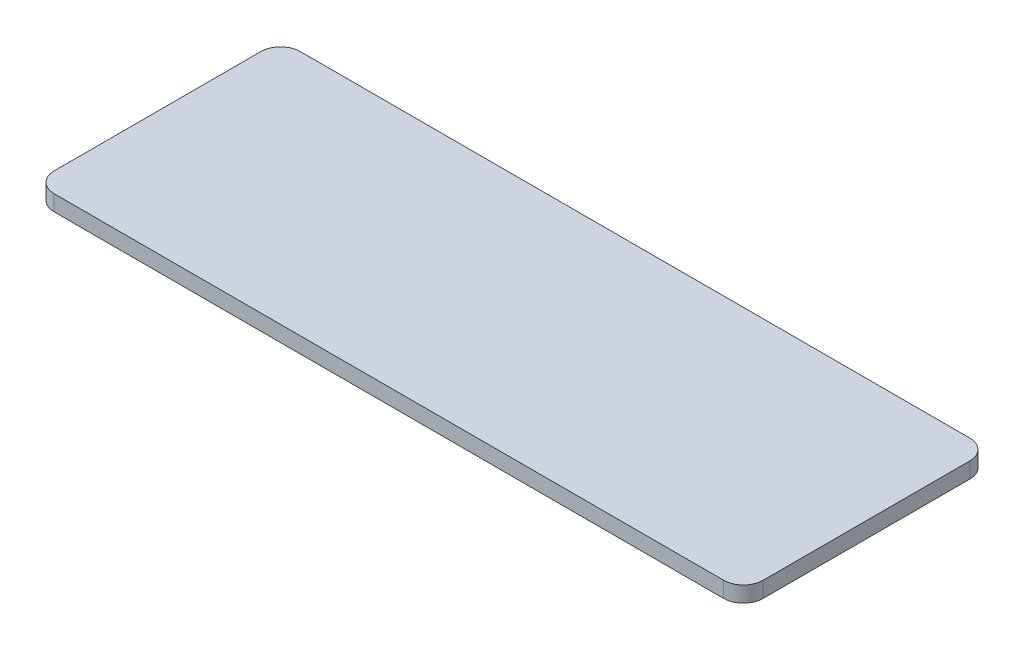
from build123d import *

# Parameters (mm, degrees)
SKETCH1_W           = 72
SKETCH1_H           = 25
BOSS_EXTRUDE1_DEPTH = 1.6
FILLET1_R           = 2


with BuildPart() as part:
    # Sketch1 → Boss-Extrude1 (new body)
    with BuildSketch(Plane(origin=(0, 0, 0), x_dir=(1, 0, 0), z_dir=(0, 1, 0))):
        with Locations((36, 12.5)):
            Rectangle(SKETCH1_W, SKETCH1_H)
    extrude(amount=BOSS_EXTRUDE1_DEPTH)

    # Fillet1
    fillet1_edges = [part.edges().sort_by_distance(p)[0] for p in [
        (0, 0.8, -25),
        (72, 0.8, -25),
        (72, 0.8, 0),
        (0, 0.8, 0),
    ]]
    fillet(fillet1_edges, radius=FILLET1_R)


solid = part.part
